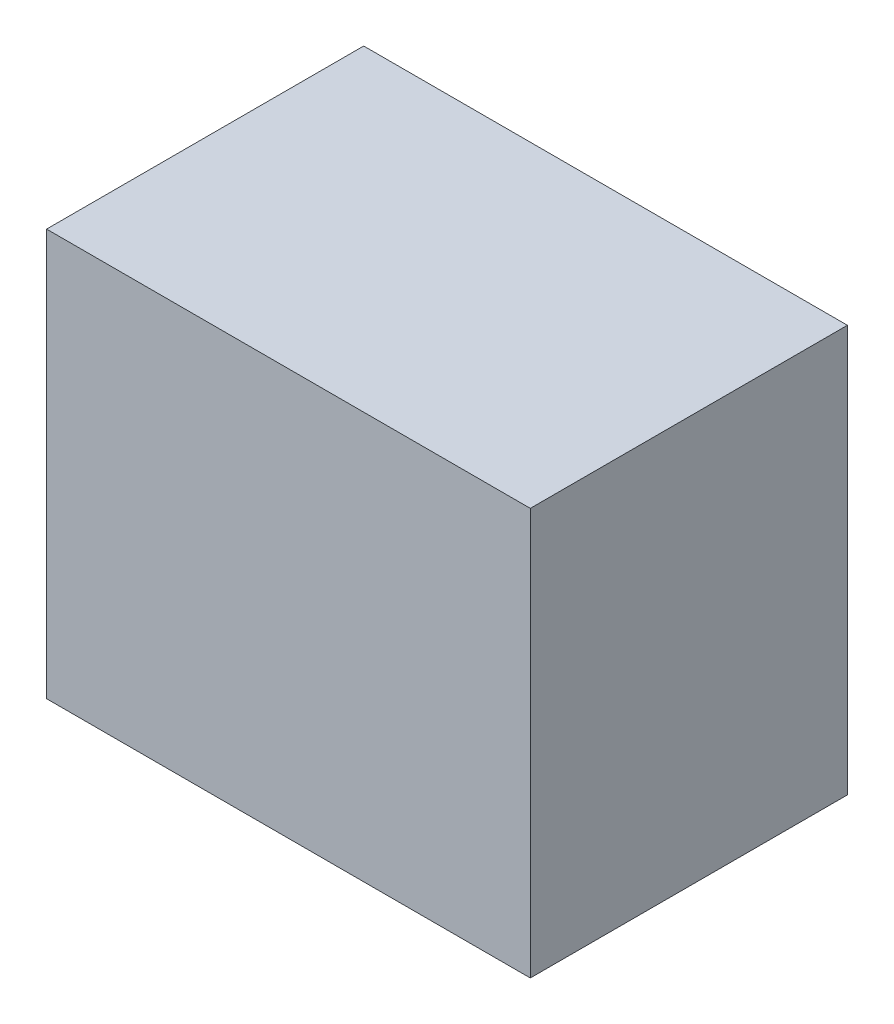
from build123d import *

# Parameters (mm, degrees)
SKETCH1_W           = 106.934
SKETCH1_H           = 70.104
BOSS_EXTRUDE1_DEPTH = 89.916


with BuildPart() as part:
    # Sketch1 → Boss-Extrude1 (new body)
    with BuildSketch(Plane(origin=(0, 0, 0), x_dir=(1, 0, 0), z_dir=(0, 1, 0))):
        with Locations((53.467, 35.052)):
            Rectangle(SKETCH1_W, SKETCH1_H)
    extrude(amount=BOSS_EXTRUDE1_DEPTH)


solid = part.part
